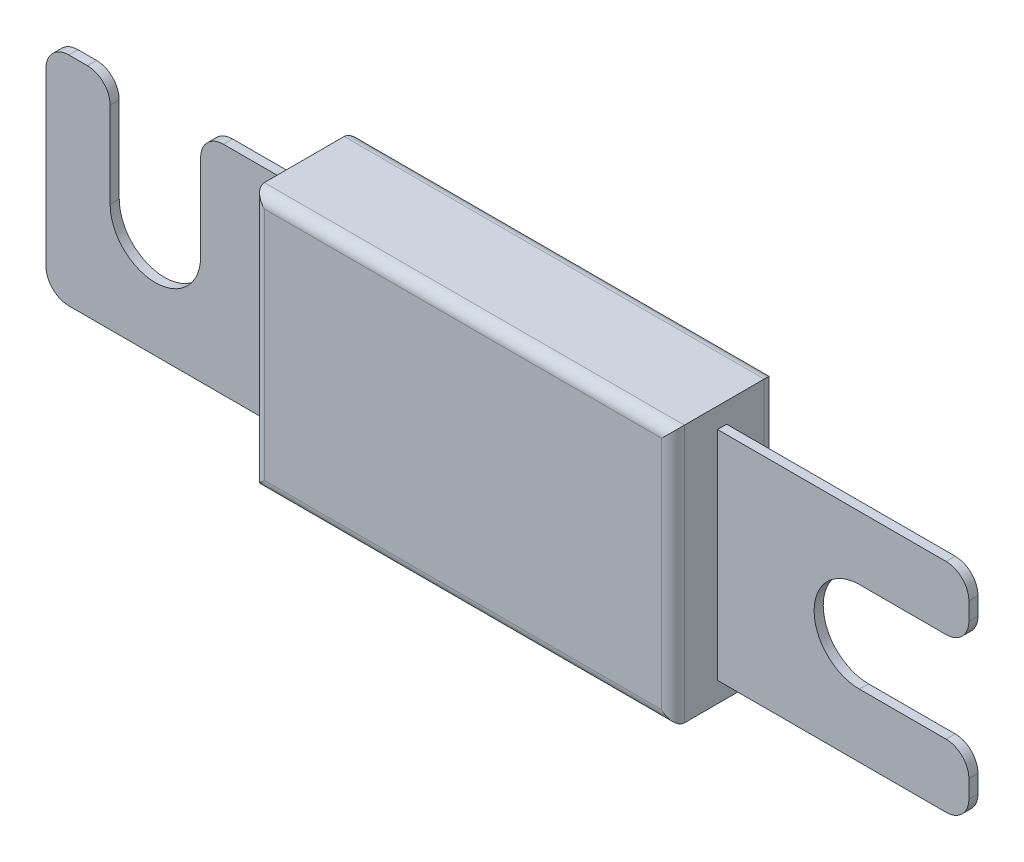
from build123d import *

# Parameters (mm, degrees)
SALIENTE_EXTRUIR1_DEPTH      = 0.8
CROQUIS2_W                   = 36.83
CROQUIS2_H                   = 22.61
SALIENTE_EXTRUIR2_DEPTH      = 3.9
SALIENTE_EXTRUIR2_DEPTH_BACK = 5.1
REDONDEO1_R                  = 1
REDONDEO2_R                  = 1


with BuildPart() as part:
    # Croquis1 → Saliente-Extruir1 (new body)
    with BuildSketch(Plane.XY):
        with BuildLine():
            Line((0, 2), (0, 17.05))
            ThreePointArc((0, 17.05), (0.585786438, 18.464213562), (2, 19.05))
            Line((2, 19.05), (3.62125, 19.05))
            ThreePointArc((3.62125, 19.05), (5.035463562, 18.464213562), (5.62125, 17.05))
            Line((5.62125, 17.05), (5.62125, 9.525))
            ThreePointArc((5.62125, 9.525), (9.59, 5.55625), (13.55875, 9.525))
            Line((13.55875, 9.525), (13.55875, 17.05))
            ThreePointArc((13.55875, 17.05), (14.144536438, 18.464213562), (15.55875, 19.05))
            Line((15.55875, 19.05), (78.91, 19.05))
            ThreePointArc((78.91, 19.05), (80.324213562, 18.464213562), (80.91, 17.05))
            Line((80.91, 17.05), (80.91, 15.49375))
            ThreePointArc((80.91, 15.49375), (80.324213562, 14.079536438), (78.91, 13.49375))
            Line((78.91, 13.49375), (71.31, 13.49375))
            ThreePointArc((71.31, 13.49375), (67.34125, 9.525), (71.31, 5.55625))
            Line((71.31, 5.55625), (78.91, 5.55625))
            ThreePointArc((78.91, 5.55625), (80.324213562, 4.970463562), (80.91, 3.55625))
            Line((80.91, 3.55625), (80.91, 2))
            ThreePointArc((80.91, 2), (80.324213562, 0.585786438), (78.91, 0))
            Line((78.91, 0), (2, 0))
            ThreePointArc((2, 0), (0.585786438, 0.585786438), (0, 2))
        make_face()
    extrude(amount=SALIENTE_EXTRUIR1_DEPTH)

    # Croquis2 → Saliente-Extruir2 (add, two sides)
    with BuildSketch(Plane.XY.offset(0.8)) as saliente_extruir2_sk:
        with Locations((40.455, 9.525)):
            Rectangle(CROQUIS2_W, CROQUIS2_H)
    extrude(amount=SALIENTE_EXTRUIR2_DEPTH)
    extrude(saliente_extruir2_sk.sketch, amount=-SALIENTE_EXTRUIR2_DEPTH_BACK)

    # Redondeo1
    redondeo1_edges = [part.edges().sort_by_distance(p)[0] for p in [
        (22.04, 9.525, -4.3),
        (58.87, 9.525, -4.3),
        (40.455, 20.83, -4.3),
        (40.455, -1.78, -4.3),
    ]]
    fillet(redondeo1_edges, radius=REDONDEO1_R)

    # Redondeo2
    redondeo2_edges = [part.edges().sort_by_distance(p)[0] for p in [
        (22.04, 9.525, 4.7),
        (40.455, -1.78, 4.7),
        (58.87, 9.525, 4.7),
        (40.455, 20.83, 4.7),
    ]]
    fillet(redondeo2_edges, radius=REDONDEO2_R)


solid = part.part
